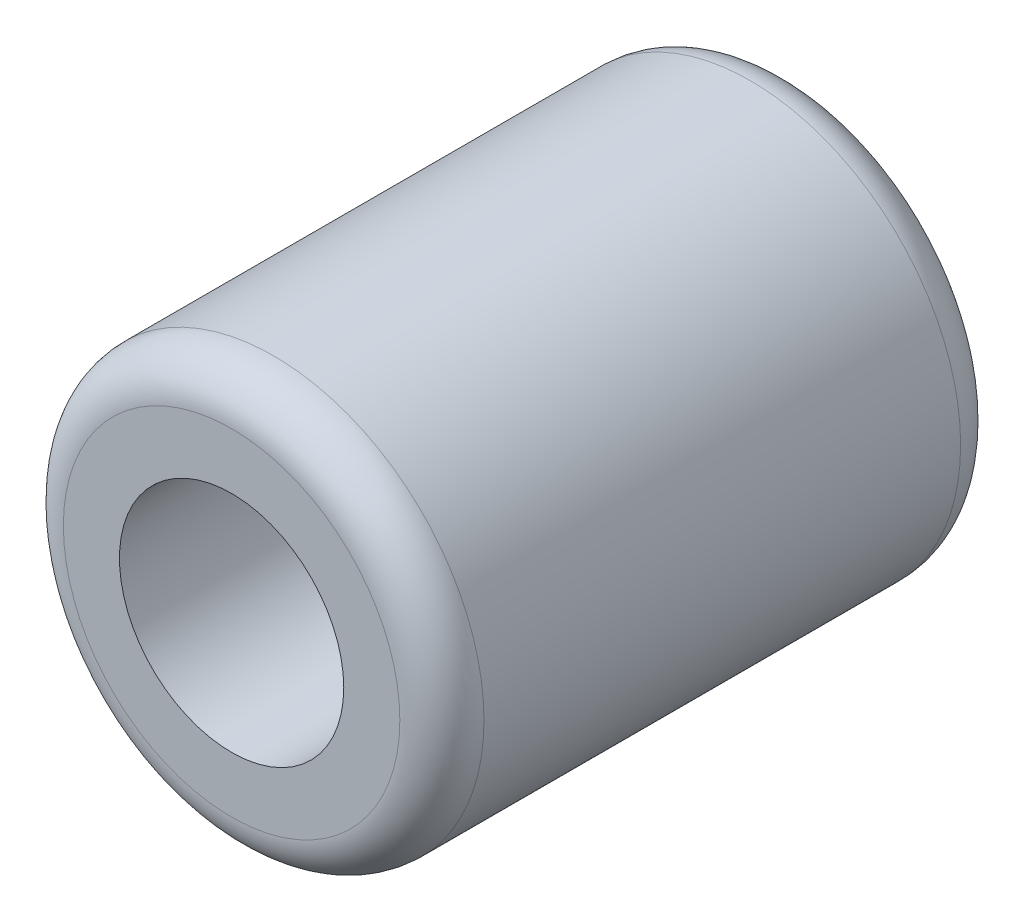
from build123d import *

# Parameters (mm, degrees)
SKETCH_1_R      = 15
SKETCH_1_R_2    = 8
EXTRUDE_1_DEPTH = 20
FILLET_1_R      = 3


with BuildPart() as part:
    # Эскиз1 → Бобышка-Вытянуть1 (new body, symmetric)
    with BuildSketch(Plane.XY):
        Circle(SKETCH_1_R)
        Circle(SKETCH_1_R_2, mode=Mode.SUBTRACT)
    extrude(amount=EXTRUDE_1_DEPTH, both=True)

    # Скругление1
    fillet_1_edges = [part.edges().sort_by_distance(p)[0] for p in [
        (-15, 0, -20),
        (-15, 0, 20),
    ]]
    fillet(fillet_1_edges, radius=FILLET_1_R)


solid = part.part
